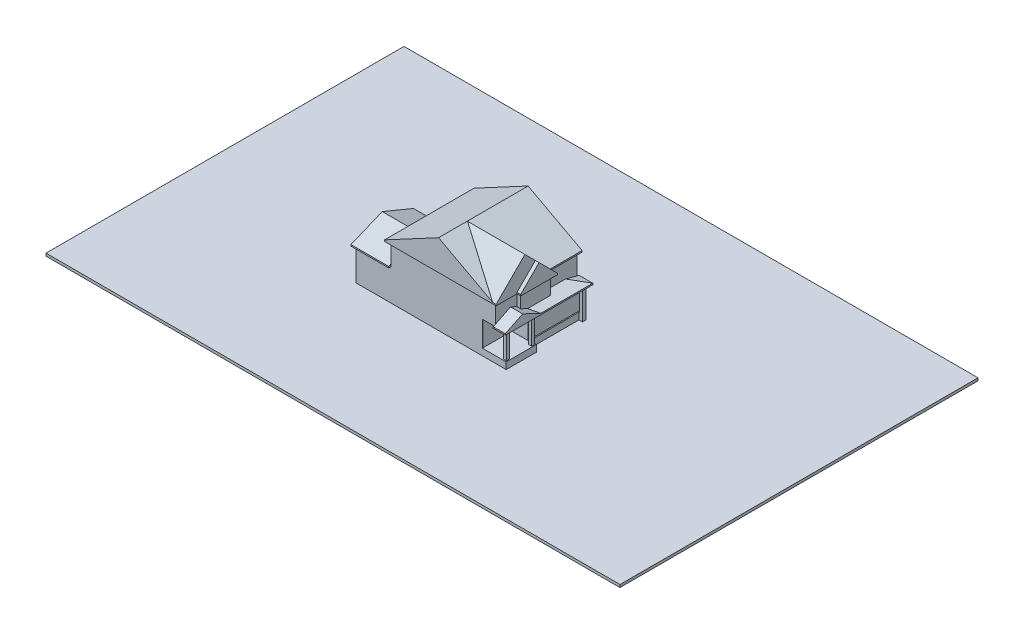
from build123d import *

# Parameters (mm, degrees)
BOSS_EXTRUDE1_DEPTH              = 2603.5
BOSS_EXTRUDE2_DEPTH              = 3022.6
BOSS_EXTRUDE3_DEPTH              = 2463.8
SKETCH4_W                        = 65697.460420921
SKETCH4_H                        = 40979.830360303
BOSS_EXTRUDE4_DEPTH              = 304.8
SKETCH5_W                        = 21895.016639369
SKETCH5_H                        = 12322.560301516
CUT_EXTRUDE1_DEPTH               = 1905
BOSS_EXTRUDE5_REACH              = 52955.248
BOSS_EXTRUDE6_REACH              = 51905.327
CUT_EXTRUDE2_DEPTH               = 1276.35
BOSS_EXTRUDE7_REACH              = 51982.038
BOSS_EXTRUDE8_DEPTH              = 406.4
CUT_EXTRUDE3_DEPTH               = 11303
BOSS_EXTRUDE9_REACH              = 47146.859
BOSS_EXTRUDE10_START             = -6572.127481
BOSS_EXTRUDE10_DEPTH             = 6572.127481
SKETCH15_W                       = 355.6
SKETCH15_H                       = 355.6
BOSS_EXTRUDE11_DEPTH             = 3022.6
BOSS_EXTRUDE12_DEPTH             = 7362.952
CUT_EXTRUDE4_DEPTH               = 304.8
CUT_EXTRUDE4_DEPTH_BACK          = 1308.1
BOSS_EXTRUDE13_REACH             = 47384.657
BOSS_EXTRUDE13_DIRECTION_2_DEPTH = 254
SKETCH19_W                       = 14484.502299334
SKETCH19_H                       = 133.052541355
BOSS_EXTRUDE14_DEPTH             = 3022.6
SKETCH20_W                       = 10445.902299334
SKETCH20_H                       = 57.769049229
BOSS_EXTRUDE15_DEPTH             = 2601.214
SKETCH22_W                       = 53.975
SKETCH22_H                       = 2463.8
BOSS_EXTRUDE17_DEPTH             = 1517.497700666
BOSS_EXTRUDE18_DEPTH             = 3022.6
BOSS_EXTRUDE19_DEPTH             = 3784.6
BOSS_EXTRUDE20_DEPTH             = 152.4
BOSS_EXTRUDE21_DEPTH             = 152.4
SKETCH27_W                       = 171.45
SKETCH27_H                       = 2870.2
CUT_EXTRUDE5_DEPTH               = 405.13


with BuildPart() as part:
    # Sketch1 → Boss-Extrude1 (new body)
    with BuildSketch(Plane(origin=(0, 0, 0), x_dir=(1, 0, 0), z_dir=(0, 1, 0))):
        Polygon((0, 0), (17208.5, 0), (17208.5, 3454.4), (16446.5, 3454.4), (16446.5, 9093.2), (16852.9, 9093.2), (16852.9, 9448.8), (16446.5, 9448.8), (3048, 9448.8), (3048, 6604), (0, 6604), align=None)
    extrude(amount=BOSS_EXTRUDE1_DEPTH)

    # Sketch2 → Boss-Extrude2 (add)
    with BuildSketch(Plane(origin=(0, 2603.5, 0), x_dir=(1, 0, 0), z_dir=(0, 1, 0))):
        Polygon((120.65, 127), (120.65, 6477), (3168.65, 6477), (3168.65, 9328.15), (16325.85, 9328.15), (16325.85, 3365.5), (14484.35, 3365.5), (14484.35, 127), align=None)
    extrude(amount=BOSS_EXTRUDE2_DEPTH)

    # Sketch3 → Boss-Extrude3 (add)
    with BuildSketch(Plane(origin=(0, 5626.1, 0), x_dir=(1, 0, 0), z_dir=(0, 1, 0))):
        Polygon((4038.6, 9490.075), (15824.2, 9490.075), (15824.2, 5832.475), (16427.45, 5832.475), (16427.45, 2435.225), (16002, 2435.225), (16002, 53.975), (4038.6, 53.975), align=None)
    extrude(amount=BOSS_EXTRUDE3_DEPTH)

    # Sketch4 → Boss-Extrude4 (add)
    with BuildSketch(Plane(origin=(0, 1841.5, 0), x_dir=(1, 0, 0), z_dir=(0, 1, 0))):
        with Locations((12173.164818329, 5698.197471797)):
            Rectangle(SKETCH4_W, SKETCH4_H)
    extrude(amount=-BOSS_EXTRUDE4_DEPTH)

    # Sketch5 → Cut-Extrude1 (cut)
    with BuildSketch(Plane.XZ.offset(-1536.7)):
        with Locations((8389.493403635, -5047.013792364)):
            Rectangle(SKETCH5_W, SKETCH5_H)
    extrude(amount=CUT_EXTRUDE1_DEPTH, mode=Mode.SUBTRACT)

    # Boss-Extrude5: up to this face of the body (flat: up to its plane)
    boss_extrude5_end = Plane(part.part.faces().sort_by_distance((4038.6, 6858, -4772.025))[0])
    # Sketch6 → Boss-Extrude5 (add, up to the picked face)
    with BuildSketch(Plane.ZY.offset(285.75), mode=Mode.PRIVATE) as boss_extrude5_sk1:
        Polygon((-127, 5626.1), (-6477, 5626.1), (-6883.4, 5626.1), (-3302, 7109.564452283), (279.4, 5626.1), align=None)
    boss_extrude5_tool1 = split(extrude(boss_extrude5_sk1.sketch, amount=-BOSS_EXTRUDE5_REACH, mode=Mode.PRIVATE), bisect_by=boss_extrude5_end, keep=Keep.BOTH, mode=Mode.PRIVATE)
    add(boss_extrude5_tool1.solids().sort_by(Axis((-285.75, 6120.588151, -3302), (1, 0, 0)))[0])

    # Boss-Extrude6: up to this plane
    boss_extrude6_end = Plane(origin=(11353.4048929, 5626.1, -6883.4), z_dir=(0, 0.9238795325112832, -0.38268343236509844))
    # Sketch8 → Boss-Extrude6 (add, up to the surface)
    with BuildSketch(Plane(origin=(0, 0, -9734.55), x_dir=(-1, 0, 0), z_dir=(0, 0, -1)), mode=Mode.PRIVATE) as boss_extrude6_sk1:
        Polygon((-4038.6, 5626.1), (-3168.65, 5626.1), (-2762.25, 5626.1), (-4038.6, 6154.781480335), align=None)
    boss_extrude6_tool1 = split(extrude(boss_extrude6_sk1.sketch, amount=-BOSS_EXTRUDE6_REACH, mode=Mode.PRIVATE), bisect_by=boss_extrude6_end, keep=Keep.BOTH, mode=Mode.PRIVATE)
    add(boss_extrude6_tool1.solids().sort_by_distance((3613.15, 5802.32716, -9734.55))[0])

    # Sketch9 → Cut-Extrude2 (cut)
    with BuildSketch(Plane.ZY.offset(-2762.25)):
        Polygon((-9734.55, 5626.1), (-8458.2, 6154.781480335), (-9734.55, 6154.781480335), align=None)
    extrude(amount=-CUT_EXTRUDE2_DEPTH, mode=Mode.SUBTRACT)

    # Boss-Extrude7: up to this face of the body (flat: up to its plane)
    boss_extrude7_end = Plane(part.part.faces().sort_by_distance((10020.3, 6858, -53.975))[0])
    # Sketch10 → Boss-Extrude7 (add, up to the picked face)
    with BuildSketch(Plane(origin=(0, 0, -9896.475), x_dir=(-1, 0, 0), z_dir=(0, 0, -1)), mode=Mode.PRIVATE) as boss_extrude7_sk1:
        Polygon((-4038.6, 8089.9), (-15824.2, 8089.9), (-16230.6, 8089.9), (-9931.4, 11456.892547581), (-3632.2, 8089.9), align=None)
    boss_extrude7_tool1 = split(extrude(boss_extrude7_sk1.sketch, amount=-BOSS_EXTRUDE7_REACH, mode=Mode.PRIVATE), bisect_by=boss_extrude7_end, keep=Keep.BOTH, mode=Mode.PRIVATE)
    add(boss_extrude7_tool1.solids().sort_by(Axis((9931.4, 9212.230849, -9896.475), (0, 0, 1)))[0])

    # Sketch11 → Boss-Extrude8 (add)
    with BuildSketch(Plane.XY.offset(-53.975)):
        Polygon((3632.2, 8089.9), (9931.4, 11456.892547581), (16230.6, 8089.9), align=None)
    extrude(amount=BOSS_EXTRUDE8_DEPTH)

    # Sketch12 → Cut-Extrude3 (cut)
    with BuildSketch(Plane.XY.offset(352.425)):
        Polygon((16002, 8089.9), (16230.6, 8089.9), (9931.4, 11456.892547581), (9817.1, 11395.797924742), align=None)
    extrude(amount=-CUT_EXTRUDE3_DEPTH, mode=Mode.SUBTRACT)

    # Boss-Extrude9: up to this plane
    boss_extrude9_end = Plane(origin=(16002, 8089.9, -10950.575), z_dir=(-0.47139673682599864, -0.8819212643483546, 0))
    # Sketch13 → Boss-Extrude9 (add, up to the surface)
    with BuildSketch(Plane(origin=(16833.85, 0, 0), x_dir=(0, 0, -1), z_dir=(1, 0, 0)), mode=Mode.PRIVATE) as boss_extrude9_sk1:
        Polygon((5832.475, 8089.9), (2435.225, 8089.9), (2028.825, 8089.9), (4133.85, 10194.925), (6238.875, 8089.9), align=None)
    boss_extrude9_tool1 = split(extrude(boss_extrude9_sk1.sketch, amount=-BOSS_EXTRUDE9_REACH, mode=Mode.PRIVATE), bisect_by=boss_extrude9_end, keep=Keep.BOTH, mode=Mode.PRIVATE)
    add(boss_extrude9_tool1.solids().sort_by_distance((16833.85, 8791.575, -4133.85))[0])

    # Sketch14 → Boss-Extrude10 (add)
    with BuildSketch(Plane(origin=(16408.4, 0, 0), x_dir=(0, 0, -1), z_dir=(1, 0, 0)).offset(BOSS_EXTRUDE10_START)):
        Polygon((-352.425, 8089.9), (2943.225, 11385.55), (4133.85, 10194.925), (2028.825, 8089.9), align=None)
    extrude(amount=BOSS_EXTRUDE10_DEPTH)

    # Sketch15 → Boss-Extrude11 (add)
    with BuildSketch(Plane(origin=(0, 2603.5, 0), x_dir=(1, 0, 0), z_dir=(0, 1, 0))):
        with Locations((16675.1, 9271)):
            Rectangle(SKETCH15_W, SKETCH15_H)
        Polygon((17106.9, 3009.811581855), (16751.3, 3009.811581855), (16751.3, 3365.411581855), (16778.823557109, 3365.411581855), (17106.9, 3365.411581855), align=None)
        with Locations((16929.1, 304.76670394)):
            Rectangle(SKETCH15_W, SKETCH15_H)
    extrude(amount=BOSS_EXTRUDE11_DEPTH)

    # Sketch16 → Boss-Extrude12 (add)
    with BuildSketch(Plane(origin=(0, 0, -9728.2), x_dir=(-1, 0, 0), z_dir=(0, 0, -1))):
        Polygon((-15824.2, 5626.1), (-17106.9, 5626.1), (-17386.3, 5626.1), (-15824.2, 6044.663433497), align=None)
    extrude(amount=-BOSS_EXTRUDE12_DEPTH)

    # Sketch17 → Cut-Extrude4 (cut, two sides)
    with BuildSketch(Plane(origin=(17132.3, 0, 0), x_dir=(0, 0, -1), z_dir=(1, 0, 0))) as cut_extrude4_sk:
        Polygon((9734.55, 5626.1), (8172.45, 6044.663433497), (9728.2, 6044.663433497), align=None)
    extrude(amount=CUT_EXTRUDE4_DEPTH, mode=Mode.SUBTRACT)
    extrude(cut_extrude4_sk.sketch, amount=-CUT_EXTRUDE4_DEPTH_BACK, mode=Mode.SUBTRACT)

    # Boss-Extrude13: up to this face of the body (flat: up to its plane)
    boss_extrude13_end = Plane(part.part.faces().sort_by_distance((16002, 6862.650151337, -1239.464598139))[0])
    # Sketch18 → Boss-Extrude13 (add, up to the picked face)
    with BuildSketch(Plane(origin=(17132.3, 0, 0), x_dir=(0, 0, -1), z_dir=(1, 0, 0)), mode=Mode.PRIVATE) as boss_extrude13_sk1:
        Polygon((-279.4, 5626.1), (1704.333383775, 6604.369044674), (3771.811581855, 5626.1), (3365.411581855, 5626.1), (126.96670394, 5626.1), align=None)
    boss_extrude13_tool1 = split(extrude(boss_extrude13_sk1.sketch, amount=-BOSS_EXTRUDE13_REACH, mode=Mode.PRIVATE), bisect_by=boss_extrude13_end, keep=Keep.BOTH, mode=Mode.PRIVATE)
    add(boss_extrude13_tool1.solids().sort_by(Axis((17132.3, 5952.189682, -1732.248322), (-1, 0, 0)))[0])

    # Sketch18 → Boss-Extrude13 direction 2 (add)
    with BuildSketch(Plane(origin=(17132.3, 0, 0), x_dir=(0, 0, -1), z_dir=(1, 0, 0))):
        Polygon((-279.4, 5626.1), (1704.333383775, 6604.369044674), (3771.811581855, 5626.1), (3365.411581855, 5626.1), (126.96670394, 5626.1), align=None)
    extrude(amount=BOSS_EXTRUDE13_DIRECTION_2_DEPTH)

    # Sketch19 → Boss-Extrude14 (add)
    with BuildSketch(Plane(origin=(0, 2603.5, 0), x_dir=(1, 0, 0), z_dir=(0, 1, 0))):
        with Locations((7242.251149667, 66.526270678)):
            Rectangle(SKETCH19_W, SKETCH19_H)
    extrude(amount=BOSS_EXTRUDE14_DEPTH)

    # Sketch20 → Boss-Extrude15 (add)
    with BuildSketch(Plane(origin=(0, 5626.1, 0), x_dir=(1, 0, 0), z_dir=(0, 1, 0))):
        with Locations((9261.551149667, 28.884524615)):
            Rectangle(SKETCH20_W, SKETCH20_H)
    extrude(amount=BOSS_EXTRUDE15_DEPTH)

    # Sketch22 → Boss-Extrude17 (add)
    with BuildSketch(Plane(origin=(14484.502299334, 0, 0), x_dir=(0, 0, -1), z_dir=(1, 0, 0))):
        with Locations((26.9875, 6858)):
            Rectangle(SKETCH22_W, SKETCH22_H)
    extrude(amount=BOSS_EXTRUDE17_DEPTH)

    # Sketch23 → Boss-Extrude18 (add)
    with BuildSketch(Plane(origin=(0, 2603.5, 0), x_dir=(1, 0, 0), z_dir=(0, 1, 0))):
        Polygon((0, 6604), (0, 133.052541355), (120.65, 133.052541355), (120.65, 6477), (3168.65, 6477), (3168.65, 9328.15), (16497.3, 9328.15), (16497.3, 9448.8), (3168.65, 9448.8), (3048, 9448.8), (3048, 6604), align=None)
    extrude(amount=BOSS_EXTRUDE18_DEPTH)

    # Sketch24 → Boss-Extrude19 (add)
    with BuildSketch(Plane.XZ.offset(-5626.1)):
        Polygon((16852.9, -9448.8), (4038.6, -9448.8), (3048, -9448.8), (3048, -9490.075), (4038.6, -9490.075), (16852.9, -9490.075), align=None)
    extrude(amount=BOSS_EXTRUDE19_DEPTH)

    # Sketch25 → Boss-Extrude20 (add)
    with BuildSketch(Plane.XZ.offset(-8089.9)):
        Polygon((3632.2, 352.425), (3632.2, -9896.475), (16002, -9896.475), (16002, -6238.875), (16833.85, -6238.875), (16833.85, -2028.825), (16408.4, -2028.825), (16408.4, 352.425), (16002, 352.425), align=None)
        Polygon((4140.2, -155.575), (4140.2, -9388.475), (15494, -9388.475), (15494, -5730.875), (16325.85, -5730.875), (16325.85, -2536.825), (15900.4, -2536.825), (15900.4, -155.575), align=None, mode=Mode.SUBTRACT)
    extrude(amount=BOSS_EXTRUDE20_DEPTH)

    # Sketch26 → Boss-Extrude21 (add)
    with BuildSketch(Plane.XZ.offset(-5626.1)):
        Polygon((4038.6, 0), (4038.6, 279.4), (-285.75, 279.4), (-285.75, -6883.4), (2762.25, -6883.4), (2762.25, -9734.55), (4038.6, -9734.55), (4038.6, -9490.075), (15824.2, -9490.075), (15824.2, -9728.2), (17386.3, -9728.2), (17386.3, -3771.811581855), (17386.3, 279.4), (16002, 279.4), (16002, 0), align=None)
        Polygon((3530.6, -508), (3530.6, -228.6), (222.25, -228.6), (222.25, -6375.4), (3270.25, -6375.4), (3270.25, -9226.55), (3530.6, -9226.55), (3530.6, -8982.075), (16332.2, -8982.075), (16332.2, -9220.2), (16878.3, -9220.2), (16878.3, -3771.811581855), (16878.3, -228.6), (16510, -228.6), (16510, -508), align=None, mode=Mode.SUBTRACT)
    extrude(amount=BOSS_EXTRUDE21_DEPTH)

    # Sketch27 → Cut-Extrude5 (cut)
    with BuildSketch(Plane.XY.offset(-9328.15)):
        with Locations((16411.575, 4038.6)):
            Rectangle(SKETCH27_W, SKETCH27_H)
    extrude(amount=-CUT_EXTRUDE5_DEPTH, mode=Mode.SUBTRACT)


solid = part.part
